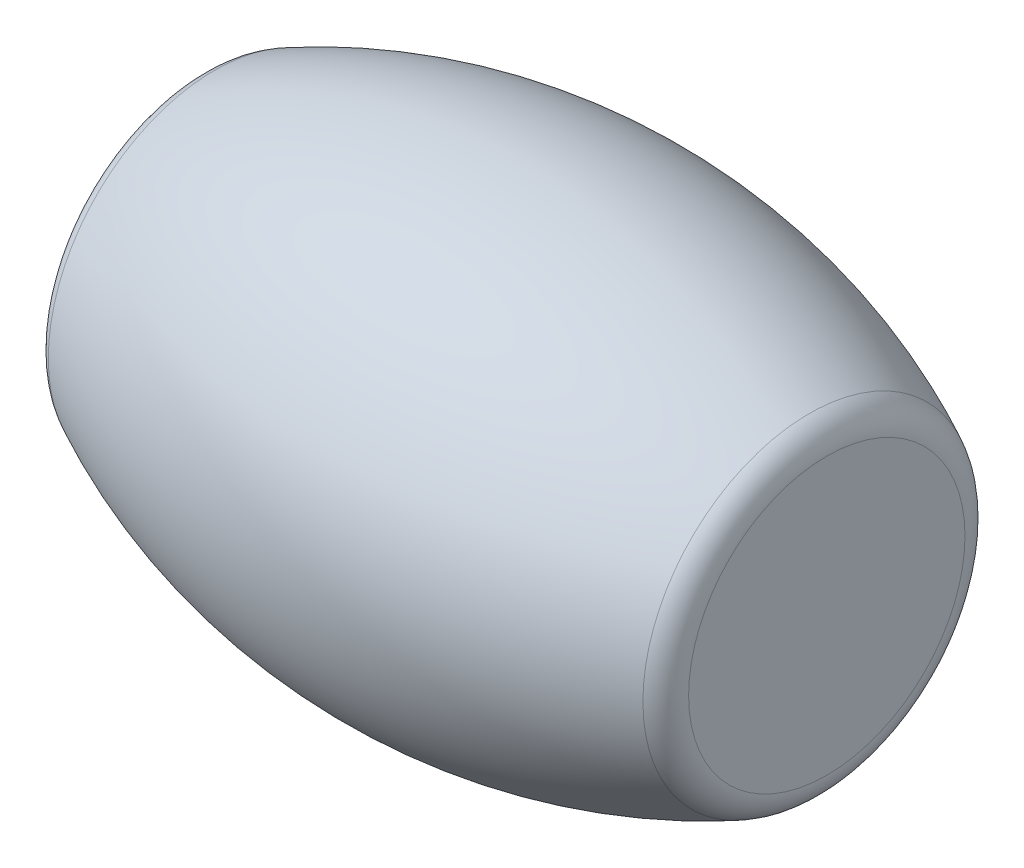
from build123d import *

# Parameters (mm, degrees)
FILLET1_R            = 2.54
FILLET1_OF_MIRROR2_R = 2.54


with BuildPart() as part:
    # Sketch1 → Revolve2 (revolve)
    with BuildSketch(Plane.XY):
        with BuildLine():
            ThreePointArc((0, 19.05), (13.090860361, 17.438441445), (25.4, 12.7))
            Line((25.4, 12.7), (25.4, 0))
            Line((25.4, 0), (0, 0))
            Line((0, 0), (0, 19.05))
        make_face()
    revolve2 = revolve(axis=Axis((0, 0, 0), (1, 0, 0)))

    # Fillet1
    fillet1_edges = [part.edges().sort_by_distance(p)[0] for p in [
        (25.4, -12.7, 0),
    ]]
    fillet(fillet1_edges, radius=FILLET1_R)

    # Mirror2: Revolve2 across plane
    add(revolve2.mirror(Plane.ZY))

    # Fillet1 of Mirror2
    fillet1_of_mirror2_edges = [part.edges().sort_by_distance(p)[0] for p in [
        (-25.4, -12.7, 0),
    ]]
    fillet(fillet1_of_mirror2_edges, radius=FILLET1_OF_MIRROR2_R)


solid = part.part
